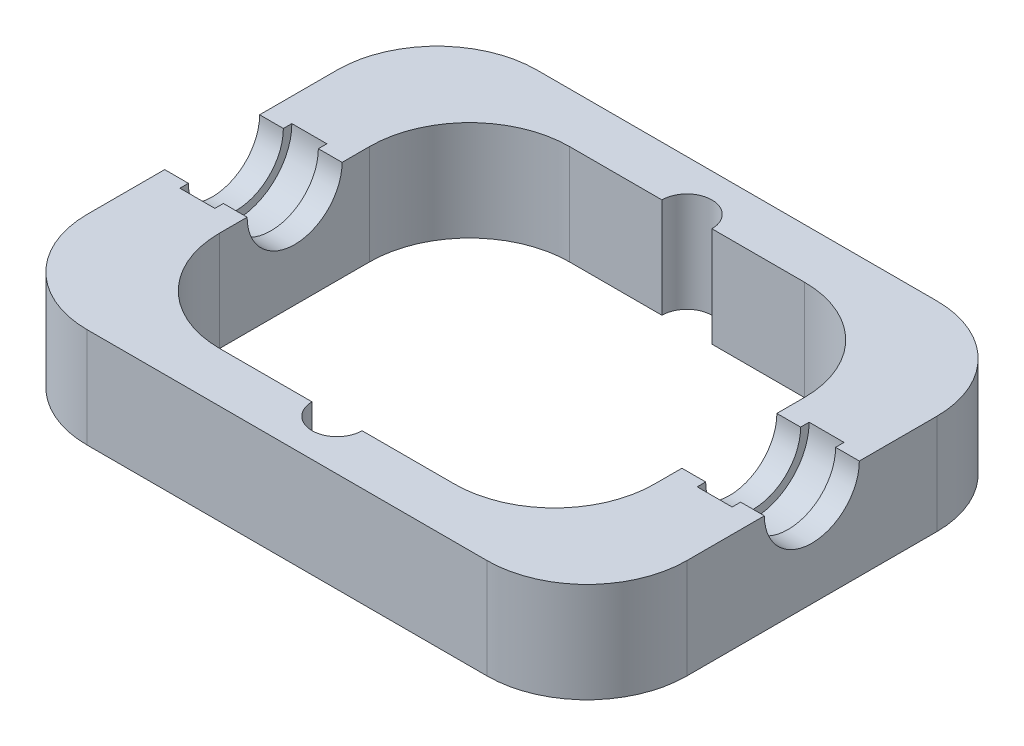
from build123d import *

# Parameters (mm, degrees)
SKETCH2_W           = 120
SKETCH2_H           = 90
SKETCH2_W_2         = 87
SKETCH2_H_2         = 70
BOSS_EXTRUDE1_DEPTH = 20
SKETCH3_W           = 7
SKETCH3_H           = 11.2
SKETCH4_R           = 9.5
CUT_EXTRUDE1_DEPTH  = 121
FILLET1_R           = 20
SKETCH5_R           = 5
CUT_EXTRUDE2_DEPTH  = 21


with BuildPart() as part:
    # Sketch2 → Boss-Extrude1 (new body)
    with BuildSketch(Plane(origin=(0, 0, 0), x_dir=(1, 0, 0), z_dir=(0, 1, 0))):
        Rectangle(SKETCH2_W, SKETCH2_H)
        Rectangle(SKETCH2_W_2, SKETCH2_H_2, mode=Mode.SUBTRACT)
    extrude(amount=BOSS_EXTRUDE1_DEPTH)

    # Sketch3 → Cut-Revolve1 (revolve, cut)
    with BuildSketch(Plane(origin=(0, 20, 0), x_dir=(1, 0, 0), z_dir=(0, 1, 0))):
        with Locations((-51.75, 5.6)):
            Rectangle(SKETCH3_W, SKETCH3_H)
        with Locations((51.75, 5.6)):
            Rectangle(SKETCH3_W, SKETCH3_H)
    revolve(axis=Axis((55.25, 20, 0), (-1, 0, 0)), mode=Mode.SUBTRACT)

    # Sketch4 → Cut-Extrude1 (cut, through all)
    with BuildSketch(Plane(origin=(60, 0, 0), x_dir=(0, 0, -1), z_dir=(1, 0, 0))):
        with Locations((0, 20)):
            Circle(SKETCH4_R)
    extrude(amount=-CUT_EXTRUDE1_DEPTH, mode=Mode.SUBTRACT)

    # Fillet1
    fillet1_edges = [part.edges().sort_by_distance(p)[0] for p in [
        (-43.5, 10, -35),
        (-43.5, 10, 35),
        (43.5, 10, 35),
        (43.5, 10, -35),
        (-60, 10, -45),
        (60, 10, -45),
        (60, 10, 45),
        (-60, 10, 45),
    ]]
    fillet(fillet1_edges, radius=FILLET1_R)

    # Sketch5 → Cut-Extrude2 (cut, through all)
    with BuildSketch(Plane(origin=(0, 20, 0), x_dir=(1, 0, 0), z_dir=(0, 1, 0))):
        with Locations((0, -35)):
            Circle(SKETCH5_R)
        with Locations((0, 35)):
            Circle(SKETCH5_R)
    extrude(amount=-CUT_EXTRUDE2_DEPTH, mode=Mode.SUBTRACT)


solid = part.part
